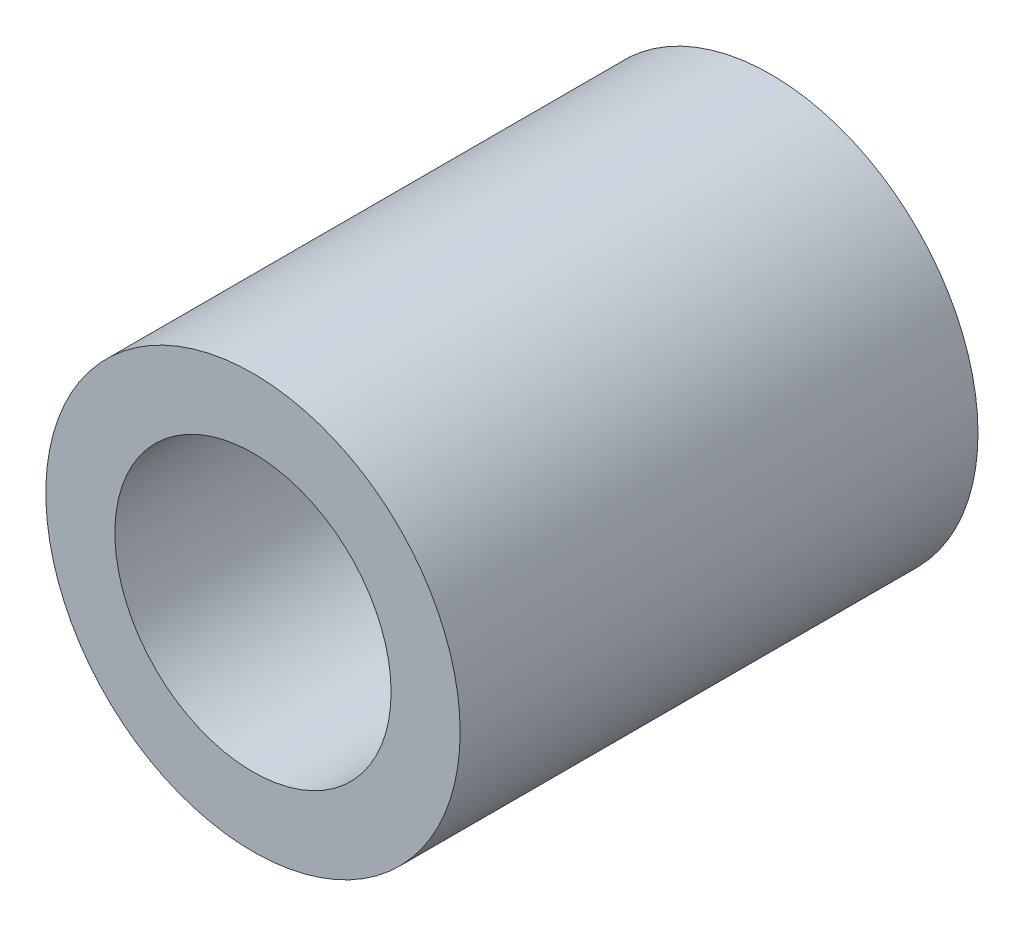
from build123d import *

# Parameters (mm, degrees)
SKETCH1_R           = 2.4
SKETCH1_R_2         = 1.6
BOSS_EXTRUDE1_DEPTH = 6


with BuildPart() as part:
    # Sketch1 → Boss-Extrude1 (new body)
    with BuildSketch(Plane.XY):
        Circle(SKETCH1_R)
        Circle(SKETCH1_R_2, mode=Mode.SUBTRACT)
    extrude(amount=BOSS_EXTRUDE1_DEPTH)


solid = part.part
